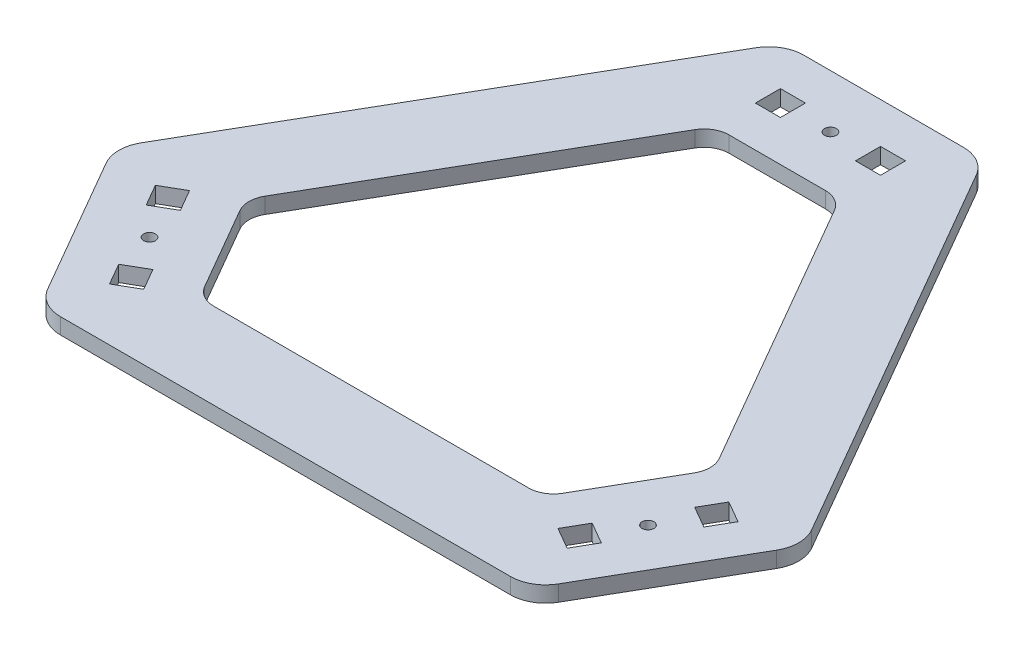
from build123d import *

# Parameters (mm, degrees)
BOSS_EXTRUDE1_DEPTH = 4.0386
SKETCH2_R           = 1.5
SKETCH2_W           = 6.35
SKETCH2_H           = 6.35
CUT_EXTRUDE1_DEPTH  = 124.208459614
CIRPATTERN1_COUNT   = 3
FILLET1_R           = 8.89
FILLET2_R           = 6.35


with BuildPart() as part:
    # Sketch1 → Boss-Extrude1 (new body)
    with BuildSketch(Plane(origin=(0, 0, 0), x_dir=(1, 0, 0), z_dir=(0, 1, 0))):
        Polygon((-25.4, 86.518604358), (25.4, 86.518604358), (87.627309274, -21.262256923), (62.227309274, -65.256347435), (-62.227309274, -65.256347435), (-87.627309274, -21.262256923), align=None)
        Polygon((-15.875, 59.51410253), (15.875, 59.51410253), (59.478224675, -16.00889798), (43.603224675, -43.50520455), (-43.603224675, -43.50520455), (-59.478224675, -16.00889798), align=None, mode=Mode.SUBTRACT)
    extrude(amount=BOSS_EXTRUDE1_DEPTH)

    # Sketch2 → Cut-Extrude1 (cut, through all)
    with BuildSketch(Plane(origin=(0, 4.0386, 0), x_dir=(1, 0, 0), z_dir=(0, 1, 0))):
        with Locations((0, 73.025)):
            Circle(SKETCH2_R)
        with Locations((12.7, 73.025)):
            Rectangle(SKETCH2_W, SKETCH2_H)
        with Locations((-12.7, 73.025)):
            Rectangle(SKETCH2_W, SKETCH2_H)
    cut_extrude1 = extrude(amount=-CUT_EXTRUDE1_DEPTH, mode=Mode.SUBTRACT)

    # CirPattern1: Cut-Extrude1 ×3 about axis
    cirpattern1_axis = Axis((0, 2.328496272, 0), (0, 1, 0))
    for i in range(1, CIRPATTERN1_COUNT):
        add(cut_extrude1.rotate(cirpattern1_axis, i * 360 / CIRPATTERN1_COUNT), mode=Mode.SUBTRACT)

    # Fillet1
    fillet1_edges = [part.edges().sort_by_distance(p)[0] for p in [
        (-25.4, 2.0193, -86.518604358),
        (25.4, 2.0193, -86.518604358),
        (87.627309274, 2.0193, 21.262256923),
        (62.227309274, 2.0193, 65.256347435),
        (-87.627309274, 2.0193, 21.262256923),
        (-62.227309274, 2.0193, 65.256347435),
    ]]
    fillet(fillet1_edges, radius=FILLET1_R)

    # Fillet2
    fillet2_edges = [part.edges().sort_by_distance(p)[0] for p in [
        (15.875, 2.0193, -59.51410253),
        (-15.875, 2.0193, -59.51410253),
        (-59.478224675, 2.0193, 16.00889798),
        (-43.603224675, 2.0193, 43.50520455),
        (59.478224675, 2.0193, 16.00889798),
        (43.603224675, 2.0193, 43.50520455),
    ]]
    fillet(fillet2_edges, radius=FILLET2_R)


solid = part.part
